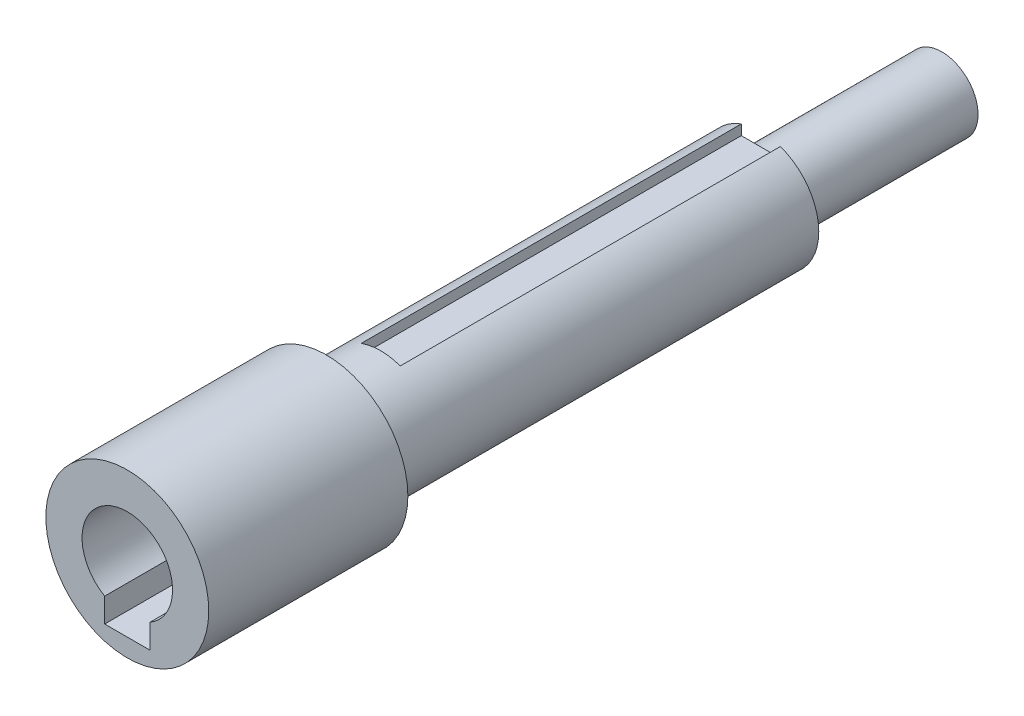
from build123d import *

# Parameters (mm, degrees)
SKETCH1_R           = 9
SKETCH1_R_2         = 5
BOSS_EXTRUDE1_DEPTH = 20
SKETCH3_R           = 6.4
BOSS_EXTRUDE2_DEPTH = 50
CUT_EXTRUDE2_DEPTH  = 16
BOSS_EXTRUDE3_START = -2
SKETCH1_3_R         = 9
BOSS_EXTRUDE3_DEPTH = 2
SKETCH1_4_R         = 5
BOSS_EXTRUDE4_DEPTH = 2
CUT_EXTRUDE3_DEPTH  = 42
SKETCH10_R          = 4
BOSS_EXTRUDE5_DEPTH = 20


with BuildPart() as part:
    # Sketch1 → Boss-Extrude1 (new body)
    with BuildSketch(Plane.XY):
        Circle(SKETCH1_R)
        Circle(SKETCH1_R_2, mode=Mode.SUBTRACT)
    extrude(amount=BOSS_EXTRUDE1_DEPTH)

    # Sketch3 → Boss-Extrude2 (add)
    with BuildSketch(Plane(origin=(0, 0, 0), x_dir=(-1, 0, 0), z_dir=(0, 0, -1))):
        Circle(SKETCH3_R)
    extrude(amount=BOSS_EXTRUDE2_DEPTH)

    # Sketch8 → Cut-Extrude2 (cut)
    with BuildSketch(Plane.XY.offset(20)):
        Polygon((0, -7), (2.5, -7), (2.5, -4.330127019), (-2.5, -4.330127019), (-2.5, -7), align=None)
    extrude(amount=-CUT_EXTRUDE2_DEPTH, mode=Mode.SUBTRACT)

    # Sketch1_3 → Boss-Extrude3 (add)
    with BuildSketch(Plane.XY.offset(BOSS_EXTRUDE3_START)):
        Circle(SKETCH1_3_R)
    extrude(amount=BOSS_EXTRUDE3_DEPTH)

    # Sketch1_4 → Boss-Extrude4 (add)
    with BuildSketch(Plane.XY):
        Circle(SKETCH1_4_R)
    extrude(amount=BOSS_EXTRUDE4_DEPTH)

    # Sketch9 → Cut-Extrude3 (cut)
    with BuildSketch(Plane(origin=(0, 0, -50), x_dir=(-1, 0, 0), z_dir=(0, 0, -1))):
        Polygon((0, 4.9), (2.16, 4.9), (2.16, 6.02448338), (0.743273512, 7.441209868), (-1.718196928, 7.441209868), (-2.16, 6.02448338), (-2.16, 4.9), align=None)
    extrude(amount=-CUT_EXTRUDE3_DEPTH, mode=Mode.SUBTRACT)

    # Sketch10 → Boss-Extrude5 (add)
    with BuildSketch(Plane(origin=(0, 0, -50), x_dir=(-1, 0, 0), z_dir=(0, 0, -1))):
        Circle(SKETCH10_R)
    extrude(amount=BOSS_EXTRUDE5_DEPTH)


solid = part.part
